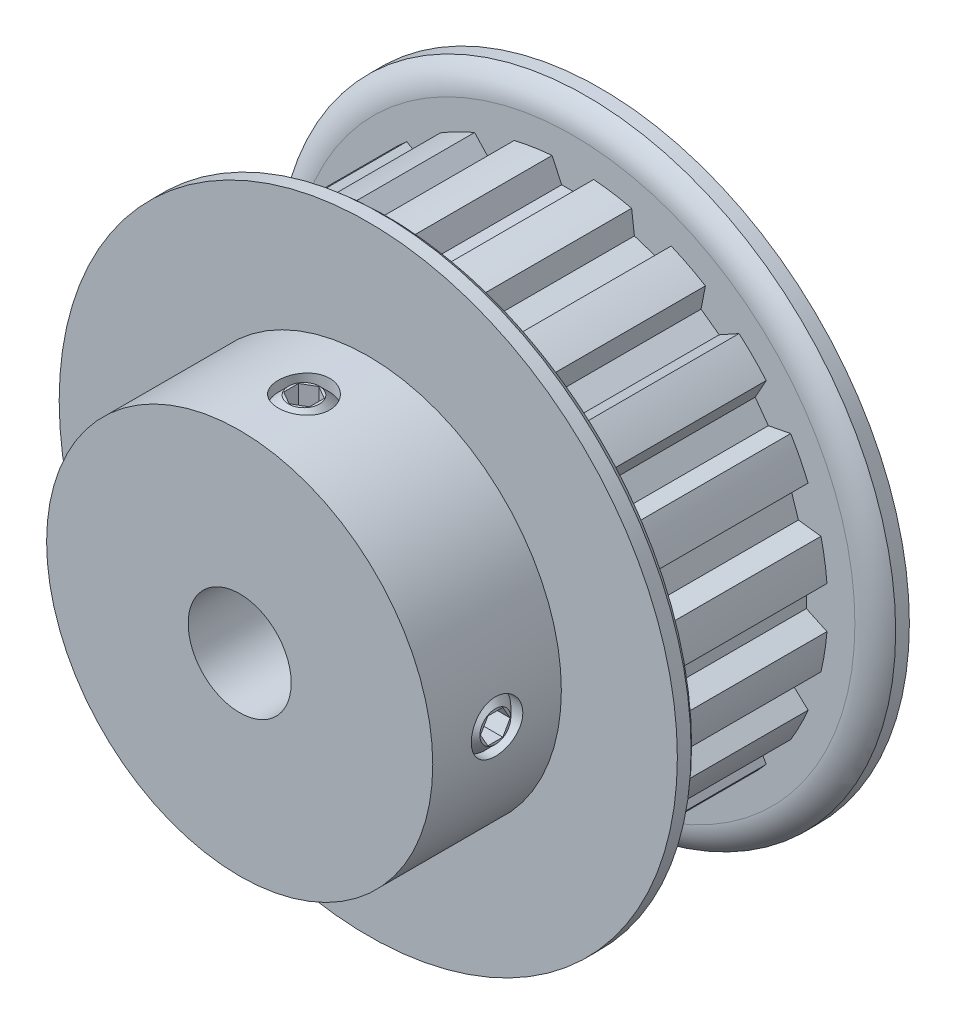
from build123d import *

# Parameters (mm, degrees)
CUT_EXTRUDE1_START = 1.4986
CUT_EXTRUDE1_DEPTH = 10.922
CIRPATTERN1_COUNT  = 20
SKETCH4_R          = 1.5875
CUT_EXTRUDE2_DEPTH = 30.142626104
CUT_EXTRUDE3_DEPTH = 1.190625
CIRPATTERN2_COUNT  = 2
CIRPATTERN2_ANGLE  = 90


with BuildPart() as part:
    # Sketch2 → Revolve1 (revolve)
    with BuildSketch(Plane(origin=(0, 0, 0), x_dir=(0, 0, -1), z_dir=(1, 0, 0)), mode=Mode.PRIVATE) as revolve1_sk:
        with BuildLine():
            Line((-11.1125, 3.175), (11.1125, 3.175))
            Line((11.1125, 3.175), (11.1125, 19.05))
            Line((11.1125, 19.05), (10.26795, 19.05))
            ThreePointArc((10.26795, 19.05), (9.646555263, 18.316132165), (9.4234, 17.380773865))
            Line((9.4234, 17.380773865), (9.4234, 15.711547731))
            Line((9.4234, 15.711547731), (-1.4986, 15.711547731))
            Line((-1.4986, 15.711547731), (-1.4986, 17.380773865))
            ThreePointArc((-1.4986, 17.380773865), (-1.721755263, 18.316132165), (-2.34315, 19.05))
            Line((-2.34315, 19.05), (-3.1877, 19.05))
            Line((-3.1877, 19.05), (-3.1877, 11.8999))
            Line((-3.1877, 11.8999), (-11.1125, 11.8999))
            Line((-11.1125, 11.8999), (-11.1125, 3.175))
        make_face()
    revolve(revolve1_sk.sketch.rotate(Axis((0, 0, 11.1125), (0, 0, -1)), 90), axis=Axis((0, 0, 11.1125), (0, 0, -1)))

    # Sketch3 → Cut-Extrude1 (cut)
    with BuildSketch(Plane.XY.offset(CUT_EXTRUDE1_START)):
        with BuildLine():
            Line((-0.690489274, 14.3891), (0.690489274, 14.3891))
            Line((0.690489274, 14.3891), (1.2827, 15.6591))
            ThreePointArc((1.2827, 15.6591), (0, 15.711547731), (-1.2827, 15.6591))
            Line((-1.2827, 15.6591), (-0.690489274, 14.3891))
        make_face()
    cut_extrude1 = extrude(amount=-CUT_EXTRUDE1_DEPTH, mode=Mode.SUBTRACT)

    # CirPattern1: Cut-Extrude1 ×20 about axis
    cirpattern1_axis = Axis((0, 0, 0), (0, 0, 1))
    for i in range(1, CIRPATTERN1_COUNT):
        add(cut_extrude1.rotate(cirpattern1_axis, i * 360 / CIRPATTERN1_COUNT), mode=Mode.SUBTRACT)

    # Sketch4 → Cut-Extrude2 (cut, through all)
    with BuildSketch(Plane(origin=(0, 0, 0), x_dir=(1, 0, 0), z_dir=(0, 1, 0))):
        with Locations(Location((0, -7.1501, 0), (0, 0, 90))):
            Circle(SKETCH4_R)
    cut_extrude2 = extrude(amount=CUT_EXTRUDE2_DEPTH, mode=Mode.SUBTRACT)

    # Sketch5 → Revolve2 (revolve)
    with BuildSketch(Plane.XY.offset(7.1501), mode=Mode.PRIVATE) as revolve2_sk:
        Polygon((0, 11.793534829), (0, 3.175), (-0.9525, 3.175), (-1.5875, 3.81), (-1.5875, 11.158534829), (-0.9525, 11.793534829), align=None)
    revolve2 = revolve(revolve2_sk.sketch.rotate(Axis((0, 0, 7.1501), (0, 1, 0)), 270), axis=Axis((0, 0, 7.1501), (0, 1, 0)))

    # Sketch6 → Cut-Extrude3 (cut)
    with BuildSketch(Plane(origin=(0, 11.793534829, 0), x_dir=(-1, 0, 0), z_dir=(0, -1, 0))):
        Polygon((0, -6.233556448), (-0.79375, -6.691828224), (-0.79375, -7.608371776), (0, -8.066643552), (0.79375, -7.608371776), (0.79375, -6.691828224), align=None)
    cut_extrude3 = extrude(amount=CUT_EXTRUDE3_DEPTH, mode=Mode.SUBTRACT)

    # CirPattern2: Cut-Extrude2, Revolve2, Cut-Extrude3 ×2 about axis
    cirpattern2_axis = Axis((0, 0, 0), (0, 0, -1))
    add([cut_extrude2.rotate(cirpattern2_axis, i * CIRPATTERN2_ANGLE / (CIRPATTERN2_COUNT - 1)) for i in range(1, CIRPATTERN2_COUNT)], mode=Mode.SUBTRACT)
    add([revolve2.rotate(cirpattern2_axis, i * CIRPATTERN2_ANGLE / (CIRPATTERN2_COUNT - 1)) for i in range(1, CIRPATTERN2_COUNT)])
    add([cut_extrude3.rotate(cirpattern2_axis, i * CIRPATTERN2_ANGLE / (CIRPATTERN2_COUNT - 1)) for i in range(1, CIRPATTERN2_COUNT)], mode=Mode.SUBTRACT)


solid = part.part
